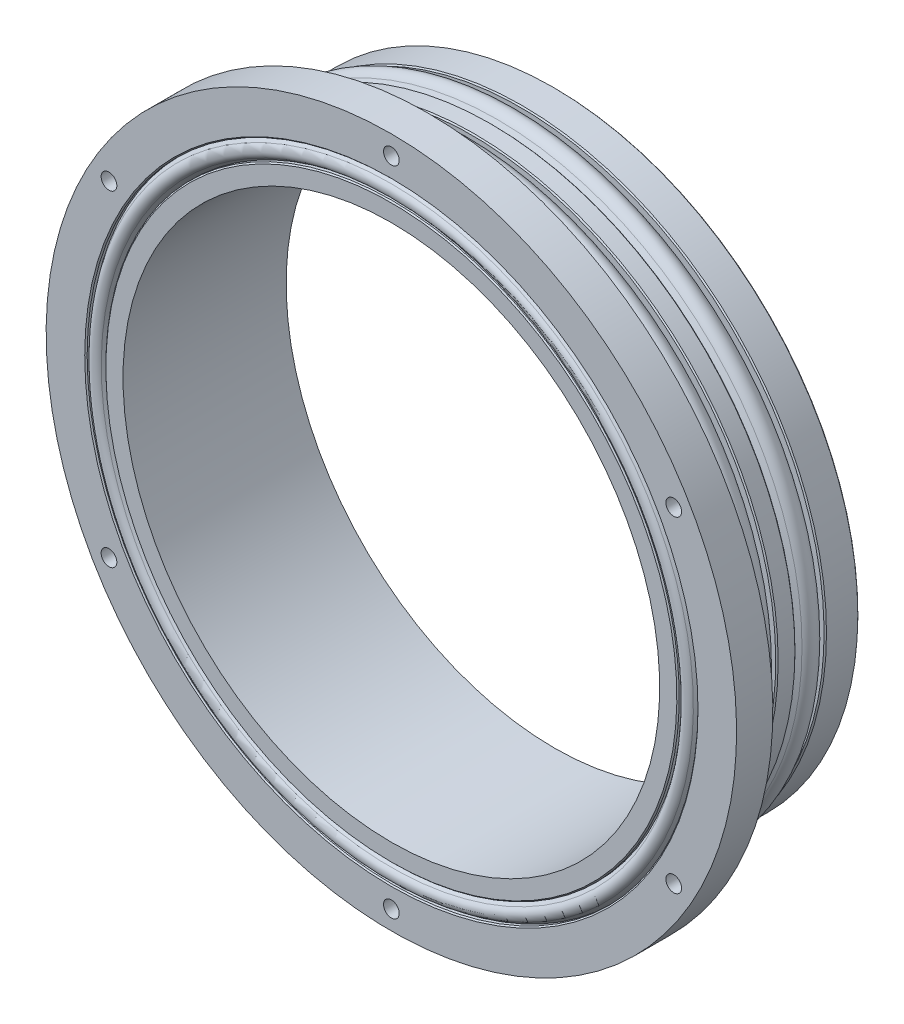
from build123d import *

# Parameters (mm, degrees)
SKETCH2_R          = 1.3
CUT_EXTRUDE1_DEPTH = 6
CHAMFER1_SIZE      = 0.2
SKETCH3_R          = 1.3
CUT_EXTRUDE2_DEPTH = 4


with BuildPart() as part:
    # Sketch1 → Revolve1 (revolve)
    with BuildSketch(Plane(origin=(0, 0, 0), x_dir=(0, 0, -1), z_dir=(1, 0, 0))):
        with BuildLine():
            Line((0, 50.419), (-5.587, 50.419))
            Line((-5.587, 50.419), (-5.587, 49.04105))
            Line((-5.587, 49.04105), (-6.547495355, 50.431651886))
            ThreePointArc((-6.547495355, 50.431651886), (-8, 51.1937), (-9.452504645, 50.431651886))
            Line((-9.452504645, 50.431651886), (-10.413, 49.04105))
            Line((-10.413, 49.04105), (-10.413, 50.419))
            Line((-10.413, 50.419), (-13.587, 50.419))
            Line((-13.587, 50.419), (-13.587, 49.04105))
            Line((-13.587, 49.04105), (-14.547495355, 50.431651886))
            ThreePointArc((-14.547495355, 50.431651886), (-16, 51.1937), (-17.452504645, 50.431651886))
            Line((-17.452504645, 50.431651886), (-18.413, 49.04105))
            Line((-18.413, 49.04105), (-18.413, 50.419))
            Line((-18.413, 50.419), (-21, 50.419))
            Line((-21, 50.419), (-21, 57.15))
            Line((-21, 57.15), (-27, 57.15))
            Line((-27, 57.15), (-27, 50.5587))
            Line((-27, 50.5587), (-26.279170235, 50.5587))
            Line((-26.279170235, 50.5587), (-27.01901462, 50.013761564))
            ThreePointArc((-27.01901462, 50.013761564), (-27.526692879, 49.0093), (-27.01901462, 48.004838436))
            Line((-27.01901462, 48.004838436), (-26.279170235, 47.4599))
            Line((-26.279170235, 47.4599), (-27, 47.4599))
            Line((-27, 47.4599), (-27, 44.419))
            Line((-27, 44.419), (0, 44.419))
            Line((0, 44.419), (0, 50.419))
        make_face()
    revolve(axis=Axis((0, 0, 0), (0, 0, 1)))

    # Sketch2 → Cut-Extrude1 (cut)
    with BuildSketch(Plane.XY.offset(27)):
        with Locations((0, 53.975)):
            Circle(SKETCH2_R)
        with Locations((46.743721169, 26.9875)):
            Circle(SKETCH2_R)
        with Locations((46.743721169, -26.9875)):
            Circle(SKETCH2_R)
        with Locations((0, -53.975)):
            Circle(SKETCH2_R)
        with Locations((-46.743721169, -26.9875)):
            Circle(SKETCH2_R)
        with Locations((-46.743721169, 26.9875)):
            Circle(SKETCH2_R)
    extrude(amount=-CUT_EXTRUDE1_DEPTH, mode=Mode.SUBTRACT)

    # Chamfer1
    chamfer1_edges = [part.edges().sort_by_distance(p)[0] for p in [
        (0, -47.4599, 27),
        (0, -50.5587, 27),
        (0, -50.419, 18.413),
        (0, -50.419, 13.587),
        (0, -50.419, 10.413),
        (0, -50.419, 5.587),
        (0, -50.419, 0),
    ]]
    chamfer(chamfer1_edges, length=CHAMFER1_SIZE)

    # Sketch3 → Cut-Extrude2 (cut)
    with BuildSketch(Plane(origin=(0, 0, 0), x_dir=(-1, 0, 0), z_dir=(0, 0, -1))):
        with Locations((-46.99, 0)):
            Circle(SKETCH3_R)
        with Locations((0, 46.99)):
            Circle(SKETCH3_R)
        with Locations((46.99, 0)):
            Circle(SKETCH3_R)
        with Locations((0, -46.99)):
            Circle(SKETCH3_R)
    extrude(amount=-CUT_EXTRUDE2_DEPTH, mode=Mode.SUBTRACT)


solid = part.part
